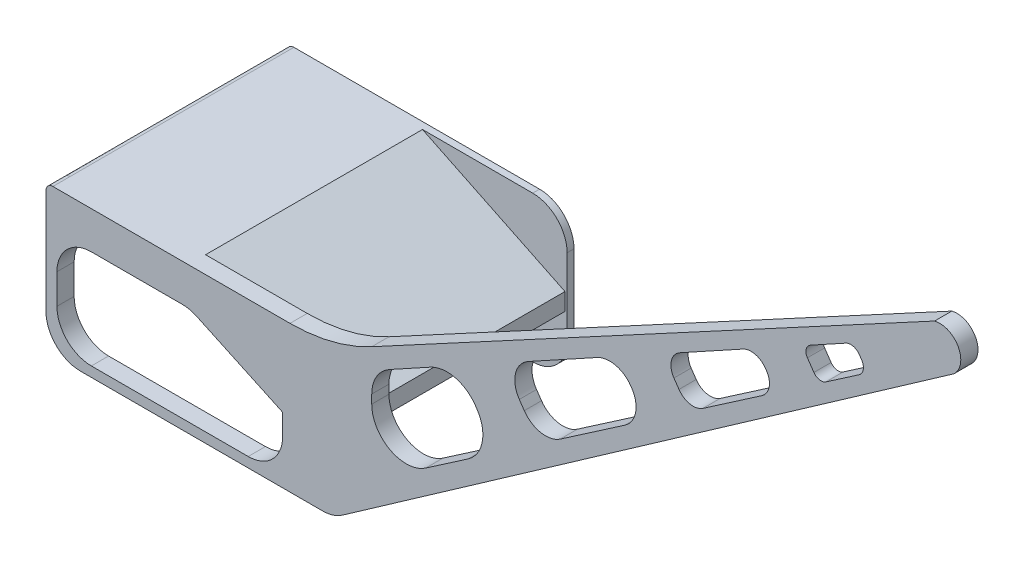
from build123d import *

# Parameters (mm, degrees)
BOSS_EXTRUDE1_DEPTH = 65
BOSS_EXTRUDE2_DEPTH = 5
FILLET1_R           = 2
BOSS_EXTRUDE3_DEPTH = 2


with BuildPart() as part:
    # Sketch1 → Boss-Extrude1 (new body)
    with BuildSketch(Plane.XY):
        Polygon((141.271101362, -12.551330892), (182.617659362, -12.551330892), (224, -32.611529859), (224, -27.611529859), (182.617659362, -7.551330892), (141.271101362, -7.551330892), align=None)
    extrude(amount=BOSS_EXTRUDE1_DEPTH)

    # Sketch2 → Boss-Extrude2 (add)
    with BuildSketch(Plane.XY.offset(65)):
        with BuildLine():
            Line((141.271101362, -17.551330892), (141.271101362, -40))
            ThreePointArc((141.271101362, -40), (144.20003355, -47.071067812), (151.271101362, -50))
            Line((151.271101362, -50), (221.609244051, -50))
            ThreePointArc((221.609244051, -50), (224.616302046, -49.537169507), (227.345008414, -48.191520443))
            Line((227.345008414, -48.191520443), (241.145272825, -38.528471273))
            Line((241.145272825, -38.528471273), (404.975681683, 76.186815997))
            ThreePointArc((404.975681683, 76.186815997), (406.218347763, 83.603069448), (399.337748937, 86.636614244))
            Line((399.337748937, 86.636614244), (235.875707721, -1.555327184))
            ThreePointArc((235.875707721, -1.555327184), (224.377798441, -6.02915992), (212.134429105, -7.551330892))
            Line((212.134429105, -7.551330892), (151.271101362, -7.551330892))
            Line((151.271101362, -7.551330892), (143.271101362, -7.551330892))
            ThreePointArc((143.271101362, -7.551330892), (141.8568878, -8.13711733), (141.271101362, -9.551330892))
            Line((141.271101362, -9.551330892), (141.271101362, -17.551330892))
        make_face()
        with BuildLine():
            Line((144.446293756, -28.410757918), (144.446293756, -37.108637926))
            ThreePointArc((144.446293756, -37.108637926), (147.375225944, -44.179705738), (154.446293756, -47.108637926))
            Line((154.446293756, -47.108637926), (200, -47.108637926))
            ThreePointArc((200, -47.108637926), (207.071067812, -44.179705738), (210, -37.108637926))
            Line((210, -37.108637926), (210, -30.978450453))
            Line((210, -30.978450453), (185.025223493, -19.345830567))
            ThreePointArc((185.025223493, -19.345830567), (182.965268196, -18.647324262), (180.803009367, -18.410757918))
            Line((180.803009367, -18.410757918), (154.446293756, -18.410757918))
            ThreePointArc((154.446293756, -18.410757918), (147.375225944, -21.339690106), (144.446293756, -28.410757918))
        make_face(mode=Mode.SUBTRACT)
        with BuildLine():
            Line((251.535159303, -24.247899123), (263.816616141, -15.81719868))
            ThreePointArc((263.816616141, -15.81719868), (267.988692729, -9.400624773), (266.401593453, -1.913318204))
            Line((266.401593453, -1.913318204), (265.970804926, -1.28576528))
            ThreePointArc((265.970804926, -1.28576528), (260.036959634, 2.784182062), (252.906809883, 1.816733956))
            Line((252.906809883, 1.816733956), (241.056141572, -4.701800674))
            ThreePointArc((241.056141572, -4.701800674), (237.267698036, -8.374334113), (235.875707721, -13.463751492))
            Line((235.875707721, -13.463751492), (235.875707721, -16.003470229))
            ThreePointArc((235.875707721, -16.003470229), (241.21708753, -24.852044007), (251.535159303, -24.247899123))
        make_face(mode=Mode.SUBTRACT)
        with BuildLine():
            Line((378.147749465, 66.305107432), (377.492648494, 67.259428411))
            ThreePointArc((377.492648494, 67.259428411), (375.712494906, 68.480412613), (373.573449981, 68.190178181))
            Line((373.573449981, 68.190178181), (363.266327618, 62.520680707))
            ThreePointArc((363.266327618, 62.520680707), (362.038869424, 60.907838903), (362.410111932, 58.915330107))
            Line((362.410111932, 58.915330107), (364.285761939, 56.182969403))
            ThreePointArc((364.285761939, 56.182969403), (365.889905415, 55.139950256), (367.761732058, 55.536725075))
            Line((367.761732058, 55.536725075), (377.372256271, 62.133943289))
            ThreePointArc((377.372256271, 62.133943289), (378.623879248, 64.058915461), (378.147749465, 66.305107432))
        make_face(mode=Mode.SUBTRACT)
        with BuildLine():
            Line((280.18309969, 4.514751946), (278.736858234, 6.621570014))
            ThreePointArc((278.736858234, 6.621570014), (277.623130083, 12.599093755), (281.305500525, 17.437619191))
            Line((281.305500525, 17.437619191), (301.361850744, 28.469759713))
            ThreePointArc((301.361850744, 28.469759713), (306.709465178, 29.195349043), (311.159851794, 26.142887908))
            Line((311.159851794, 26.142887908), (311.329646681, 25.895538523))
            ThreePointArc((311.329646681, 25.895538523), (312.519971137, 20.280058597), (309.390913697, 15.467628166))
            Line((309.390913697, 15.467628166), (290.611010047, 2.576018962))
            ThreePointArc((290.611010047, 2.576018962), (284.995530121, 1.385694505), (280.18309969, 4.514751946))
        make_face(mode=Mode.SUBTRACT)
        with BuildLine():
            Line((325.111152918, 32.323608673), (323.645737546, 34.45835842))
            ThreePointArc((323.645737546, 34.45835842), (322.903252531, 38.443376012), (325.358168918, 41.66905962))
            Line((325.358168918, 41.66905962), (343.672425355, 51.742931547))
            ThreePointArc((343.672425355, 51.742931547), (347.237500231, 52.2266556), (350.204422877, 50.191681929))
            Line((350.204422877, 50.191681929), (350.504255702, 49.754899253))
            ThreePointArc((350.504255702, 49.754899253), (351.297805339, 46.011245969), (349.211767046, 42.802959015))
            Line((349.211767046, 42.802959015), (332.063093156, 31.031120017))
            ThreePointArc((332.063093156, 31.031120017), (328.319439871, 30.237570379), (325.111152918, 32.323608673))
        make_face(mode=Mode.SUBTRACT)
    extrude(amount=BOSS_EXTRUDE2_DEPTH)

    # Fillet1
    fillet1_edges = [part.edges().sort_by_distance(p)[0] for p in [
        (141.271101362, -7.551330892, 32.5),
    ]]
    fillet(fillet1_edges, radius=FILLET1_R)

    # Sketch3 → Boss-Extrude3 (add)
    with BuildSketch(Plane(origin=(0, 0, 0), x_dir=(-1, 0, 0), z_dir=(0, 0, -1))):
        with BuildLine():
            Line((-141.271101362, -26.275665446), (-141.271101362, -40.012233887))
            ThreePointArc((-141.271101362, -40.012233887), (-144.20003355, -47.083301699), (-151.271101362, -50.012233887))
            Line((-151.271101362, -50.012233887), (-214.616302046, -50.012233887))
            ThreePointArc((-214.616302046, -50.012233887), (-221.687369858, -47.083301699), (-224.616302046, -40.012233887))
            Line((-224.616302046, -40.012233887), (-224.616302046, -26.275665446))
            Line((-224.616302046, -26.275665446), (-224.616302193, -17.551331061))
            ThreePointArc((-224.616302193, -17.551331061), (-221.687370065, -10.48026314), (-214.616302193, -7.551330892))
            Line((-214.616302193, -7.551330892), (-151.271101362, -7.551330892))
            ThreePointArc((-151.271101362, -7.551330892), (-144.20003355, -10.48026308), (-141.271101362, -17.551330892))
            Line((-141.271101362, -17.551330892), (-141.271101362, -26.275665446))
        make_face()
    extrude(amount=-BOSS_EXTRUDE3_DEPTH)


solid = part.part
